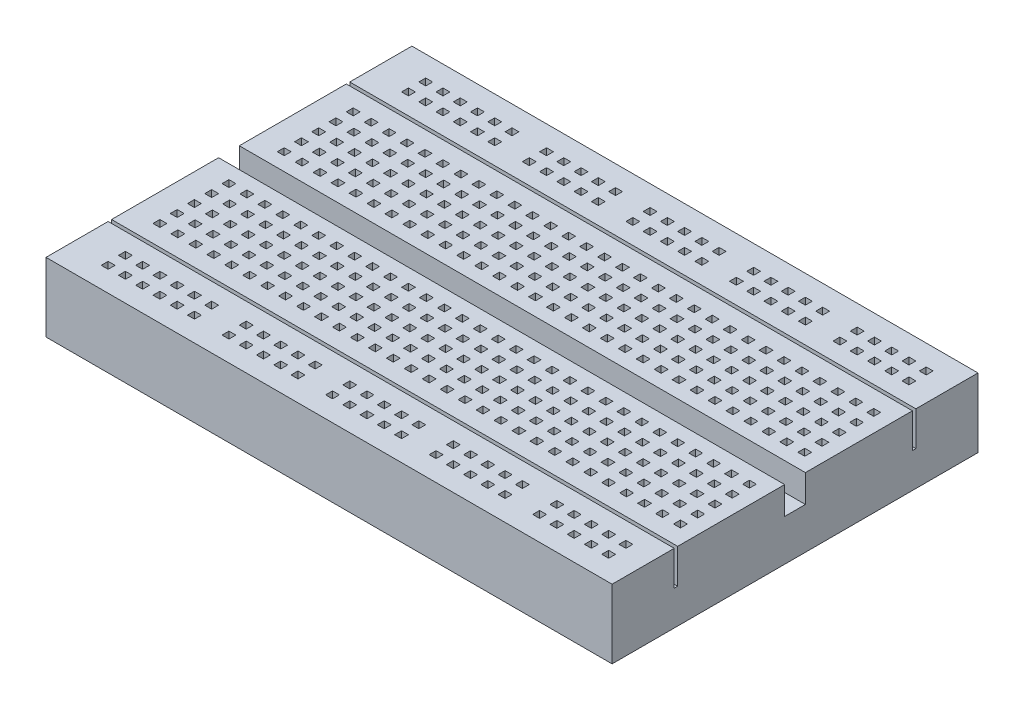
from build123d import *

# Parameters (mm, degrees)
SKETCH_1_W          = 82
SKETCH_1_H          = 53
EXTRUDE_1_DEPTH     = 10
SKETCH_2_W          = 82
SKETCH_2_H          = 3
CUT_EXTRUDE_1_DEPTH = 4
SKETCH_3_W          = 1
SKETCH_3_H          = 1
CUT_EXTRUDE_2_DEPTH = 5
SKETCH_4_W          = 1
SKETCH_4_H          = 1
CUT_EXTRUDE_3_DEPTH = 5
SKETCH_5_W          = 82
SKETCH_5_H          = 0.5
CUT_EXTRUDE_4_DEPTH = 5


with BuildPart() as part:
    # Эскиз1 → Бобышка-Вытянуть1 (new body)
    with BuildSketch(Plane(origin=(0, 0, 0), x_dir=(1, 0, 0), z_dir=(0, 1, 0))):
        Rectangle(SKETCH_1_W, SKETCH_1_H)
    extrude(amount=EXTRUDE_1_DEPTH)

    # Эскиз2 → Вырез-Вытянуть1 (cut)
    with BuildSketch(Plane(origin=(0, 10, 0), x_dir=(1, 0, 0), z_dir=(0, 1, 0))):
        Rectangle(SKETCH_2_W, SKETCH_2_H)
    extrude(amount=-CUT_EXTRUDE_1_DEPTH, mode=Mode.SUBTRACT)

    # Эскиз3 → Вырез-Вытянуть2 (cut)
    with BuildSketch(Plane(origin=(0, 10, 0), x_dir=(1, 0, 0), z_dir=(0, 1, 0))):
        with Locations((-35.5, -23)):
            Rectangle(SKETCH_3_W, SKETCH_3_H)
        with Locations((-33, -23)):
            Rectangle(SKETCH_3_W, SKETCH_3_H)
        with Locations((-30.5, -23)):
            Rectangle(SKETCH_3_W, SKETCH_3_H)
        with Locations((-28, -23)):
            Rectangle(SKETCH_3_W, SKETCH_3_H)
        with Locations((-25.5, -23)):
            Rectangle(SKETCH_3_W, SKETCH_3_H)
        with Locations((-23, -23)):
            Rectangle(SKETCH_3_W, SKETCH_3_H)
        with Locations((-18, -23)):
            Rectangle(SKETCH_3_W, SKETCH_3_H)
        with Locations((-15.5, -23)):
            Rectangle(SKETCH_3_W, SKETCH_3_H)
        with Locations((-13, -23)):
            Rectangle(SKETCH_3_W, SKETCH_3_H)
        with Locations((-10.5, -23)):
            Rectangle(SKETCH_3_W, SKETCH_3_H)
        with Locations((-8, -23)):
            Rectangle(SKETCH_3_W, SKETCH_3_H)
        with Locations((-3, -23)):
            Rectangle(SKETCH_3_W, SKETCH_3_H)
        with Locations((-0.5, -23)):
            Rectangle(SKETCH_3_W, SKETCH_3_H)
        with Locations((2, -23)):
            Rectangle(SKETCH_3_W, SKETCH_3_H)
        with Locations((4.5, -23)):
            Rectangle(SKETCH_3_W, SKETCH_3_H)
        with Locations((7, -23)):
            Rectangle(SKETCH_3_W, SKETCH_3_H)
        with Locations((12, -23)):
            Rectangle(SKETCH_3_W, SKETCH_3_H)
        with Locations((14.5, -23)):
            Rectangle(SKETCH_3_W, SKETCH_3_H)
        with Locations((17, -23)):
            Rectangle(SKETCH_3_W, SKETCH_3_H)
        with Locations((19.5, -23)):
            Rectangle(SKETCH_3_W, SKETCH_3_H)
        with Locations((22, -23)):
            Rectangle(SKETCH_3_W, SKETCH_3_H)
        with Locations((27, -23)):
            Rectangle(SKETCH_3_W, SKETCH_3_H)
        with Locations((29.5, -23)):
            Rectangle(SKETCH_3_W, SKETCH_3_H)
        with Locations((32, -23)):
            Rectangle(SKETCH_3_W, SKETCH_3_H)
        with Locations((34.5, -23)):
            Rectangle(SKETCH_3_W, SKETCH_3_H)
        with Locations((37, -23)):
            Rectangle(SKETCH_3_W, SKETCH_3_H)
        with Locations((-33, -20.5)):
            Rectangle(SKETCH_3_W, SKETCH_3_H)
        with Locations((-30.5, -20.5)):
            Rectangle(SKETCH_3_W, SKETCH_3_H)
        with Locations((-28, -20.5)):
            Rectangle(SKETCH_3_W, SKETCH_3_H)
        with Locations((-25.5, -20.5)):
            Rectangle(SKETCH_3_W, SKETCH_3_H)
        with Locations((-23, -20.5)):
            Rectangle(SKETCH_3_W, SKETCH_3_H)
        with Locations((-18, -20.5)):
            Rectangle(SKETCH_3_W, SKETCH_3_H)
        with Locations((-15.5, -20.5)):
            Rectangle(SKETCH_3_W, SKETCH_3_H)
        with Locations((-13, -20.5)):
            Rectangle(SKETCH_3_W, SKETCH_3_H)
        with Locations((-10.5, -20.5)):
            Rectangle(SKETCH_3_W, SKETCH_3_H)
        with Locations((-8, -20.5)):
            Rectangle(SKETCH_3_W, SKETCH_3_H)
        with Locations((-3, -20.5)):
            Rectangle(SKETCH_3_W, SKETCH_3_H)
        with Locations((-0.5, -20.5)):
            Rectangle(SKETCH_3_W, SKETCH_3_H)
        with Locations((2, -20.5)):
            Rectangle(SKETCH_3_W, SKETCH_3_H)
        with Locations((4.5, -20.5)):
            Rectangle(SKETCH_3_W, SKETCH_3_H)
        with Locations((7, -20.5)):
            Rectangle(SKETCH_3_W, SKETCH_3_H)
        with Locations((12, -20.5)):
            Rectangle(SKETCH_3_W, SKETCH_3_H)
        with Locations((14.5, -20.5)):
            Rectangle(SKETCH_3_W, SKETCH_3_H)
        with Locations((17, -20.5)):
            Rectangle(SKETCH_3_W, SKETCH_3_H)
        with Locations((19.5, -20.5)):
            Rectangle(SKETCH_3_W, SKETCH_3_H)
        with Locations((22, -20.5)):
            Rectangle(SKETCH_3_W, SKETCH_3_H)
        with Locations((27, -20.5)):
            Rectangle(SKETCH_3_W, SKETCH_3_H)
        with Locations((29.5, -20.5)):
            Rectangle(SKETCH_3_W, SKETCH_3_H)
        with Locations((32, -20.5)):
            Rectangle(SKETCH_3_W, SKETCH_3_H)
        with Locations((34.5, -20.5)):
            Rectangle(SKETCH_3_W, SKETCH_3_H)
        with Locations((37, -20.5)):
            Rectangle(SKETCH_3_W, SKETCH_3_H)
        with Locations((-35.5, -20.5)):
            Rectangle(SKETCH_3_W, SKETCH_3_H)
    cut_extrude_2 = extrude(amount=-CUT_EXTRUDE_2_DEPTH, mode=Mode.SUBTRACT)

    # Эскиз4 → Вырез-Вытянуть3 (cut)
    with BuildSketch(Plane(origin=(0, 10, 0), x_dir=(1, 0, 0), z_dir=(0, 1, 0))):
        with Locations((-37, -14)):
            Rectangle(SKETCH_4_W, SKETCH_4_H)
        with Locations((-34.4, -14)):
            Rectangle(SKETCH_4_W, SKETCH_4_H)
        with Locations((-31.8, -14)):
            Rectangle(SKETCH_4_W, SKETCH_4_H)
        with Locations((-29.2, -14)):
            Rectangle(SKETCH_4_W, SKETCH_4_H)
        with Locations((-26.6, -14)):
            Rectangle(SKETCH_4_W, SKETCH_4_H)
        with Locations((-24, -14)):
            Rectangle(SKETCH_4_W, SKETCH_4_H)
        with Locations((-21.4, -14)):
            Rectangle(SKETCH_4_W, SKETCH_4_H)
        with Locations((-18.8, -14)):
            Rectangle(SKETCH_4_W, SKETCH_4_H)
        with Locations((-16.2, -14)):
            Rectangle(SKETCH_4_W, SKETCH_4_H)
        with Locations((-13.6, -14)):
            Rectangle(SKETCH_4_W, SKETCH_4_H)
        with Locations((-11, -14)):
            Rectangle(SKETCH_4_W, SKETCH_4_H)
        with Locations((-8.4, -14)):
            Rectangle(SKETCH_4_W, SKETCH_4_H)
        with Locations((-5.8, -14)):
            Rectangle(SKETCH_4_W, SKETCH_4_H)
        with Locations((-3.2, -14)):
            Rectangle(SKETCH_4_W, SKETCH_4_H)
        with Locations((-0.6, -14)):
            Rectangle(SKETCH_4_W, SKETCH_4_H)
        with Locations((2, -14)):
            Rectangle(SKETCH_4_W, SKETCH_4_H)
        with Locations((4.6, -14)):
            Rectangle(SKETCH_4_W, SKETCH_4_H)
        with Locations((7.2, -14)):
            Rectangle(SKETCH_4_W, SKETCH_4_H)
        with Locations((9.8, -14)):
            Rectangle(SKETCH_4_W, SKETCH_4_H)
        with Locations((12.4, -14)):
            Rectangle(SKETCH_4_W, SKETCH_4_H)
        with Locations((15, -14)):
            Rectangle(SKETCH_4_W, SKETCH_4_H)
        with Locations((17.6, -14)):
            Rectangle(SKETCH_4_W, SKETCH_4_H)
        with Locations((20.2, -14)):
            Rectangle(SKETCH_4_W, SKETCH_4_H)
        with Locations((22.8, -14)):
            Rectangle(SKETCH_4_W, SKETCH_4_H)
        with Locations((25.4, -14)):
            Rectangle(SKETCH_4_W, SKETCH_4_H)
        with Locations((28, -14)):
            Rectangle(SKETCH_4_W, SKETCH_4_H)
        with Locations((30.6, -14)):
            Rectangle(SKETCH_4_W, SKETCH_4_H)
        with Locations((33.2, -14)):
            Rectangle(SKETCH_4_W, SKETCH_4_H)
        with Locations((35.8, -14)):
            Rectangle(SKETCH_4_W, SKETCH_4_H)
        with Locations((38.4, -14)):
            Rectangle(SKETCH_4_W, SKETCH_4_H)
        with Locations((-34.4, -11.5)):
            Rectangle(SKETCH_4_W, SKETCH_4_H)
        with Locations((-31.8, -11.5)):
            Rectangle(SKETCH_4_W, SKETCH_4_H)
        with Locations((-29.2, -11.5)):
            Rectangle(SKETCH_4_W, SKETCH_4_H)
        with Locations((-26.6, -11.5)):
            Rectangle(SKETCH_4_W, SKETCH_4_H)
        with Locations((-24, -11.5)):
            Rectangle(SKETCH_4_W, SKETCH_4_H)
        with Locations((-21.4, -11.5)):
            Rectangle(SKETCH_4_W, SKETCH_4_H)
        with Locations((-18.8, -11.5)):
            Rectangle(SKETCH_4_W, SKETCH_4_H)
        with Locations((-16.2, -11.5)):
            Rectangle(SKETCH_4_W, SKETCH_4_H)
        with Locations((-13.6, -11.5)):
            Rectangle(SKETCH_4_W, SKETCH_4_H)
        with Locations((-11, -11.5)):
            Rectangle(SKETCH_4_W, SKETCH_4_H)
        with Locations((-8.4, -11.5)):
            Rectangle(SKETCH_4_W, SKETCH_4_H)
        with Locations((-5.8, -11.5)):
            Rectangle(SKETCH_4_W, SKETCH_4_H)
        with Locations((-3.2, -11.5)):
            Rectangle(SKETCH_4_W, SKETCH_4_H)
        with Locations((-0.6, -11.5)):
            Rectangle(SKETCH_4_W, SKETCH_4_H)
        with Locations((2, -11.5)):
            Rectangle(SKETCH_4_W, SKETCH_4_H)
        with Locations((4.6, -11.5)):
            Rectangle(SKETCH_4_W, SKETCH_4_H)
        with Locations((7.2, -11.5)):
            Rectangle(SKETCH_4_W, SKETCH_4_H)
        with Locations((9.8, -11.5)):
            Rectangle(SKETCH_4_W, SKETCH_4_H)
        with Locations((12.4, -11.5)):
            Rectangle(SKETCH_4_W, SKETCH_4_H)
        with Locations((15, -11.5)):
            Rectangle(SKETCH_4_W, SKETCH_4_H)
        with Locations((17.6, -11.5)):
            Rectangle(SKETCH_4_W, SKETCH_4_H)
        with Locations((20.2, -11.5)):
            Rectangle(SKETCH_4_W, SKETCH_4_H)
        with Locations((22.8, -11.5)):
            Rectangle(SKETCH_4_W, SKETCH_4_H)
        with Locations((25.4, -11.5)):
            Rectangle(SKETCH_4_W, SKETCH_4_H)
        with Locations((28, -11.5)):
            Rectangle(SKETCH_4_W, SKETCH_4_H)
        with Locations((30.6, -11.5)):
            Rectangle(SKETCH_4_W, SKETCH_4_H)
        with Locations((33.2, -11.5)):
            Rectangle(SKETCH_4_W, SKETCH_4_H)
        with Locations((35.8, -11.5)):
            Rectangle(SKETCH_4_W, SKETCH_4_H)
        with Locations((38.4, -11.5)):
            Rectangle(SKETCH_4_W, SKETCH_4_H)
        with Locations((-34.4, -9)):
            Rectangle(SKETCH_4_W, SKETCH_4_H)
        with Locations((-31.8, -9)):
            Rectangle(SKETCH_4_W, SKETCH_4_H)
        with Locations((-29.2, -9)):
            Rectangle(SKETCH_4_W, SKETCH_4_H)
        with Locations((-26.6, -9)):
            Rectangle(SKETCH_4_W, SKETCH_4_H)
        with Locations((-24, -9)):
            Rectangle(SKETCH_4_W, SKETCH_4_H)
        with Locations((-21.4, -9)):
            Rectangle(SKETCH_4_W, SKETCH_4_H)
        with Locations((-18.8, -9)):
            Rectangle(SKETCH_4_W, SKETCH_4_H)
        with Locations((-16.2, -9)):
            Rectangle(SKETCH_4_W, SKETCH_4_H)
        with Locations((-13.6, -9)):
            Rectangle(SKETCH_4_W, SKETCH_4_H)
        with Locations((-11, -9)):
            Rectangle(SKETCH_4_W, SKETCH_4_H)
        with Locations((-8.4, -9)):
            Rectangle(SKETCH_4_W, SKETCH_4_H)
        with Locations((-5.8, -9)):
            Rectangle(SKETCH_4_W, SKETCH_4_H)
        with Locations((-3.2, -9)):
            Rectangle(SKETCH_4_W, SKETCH_4_H)
        with Locations((-0.6, -9)):
            Rectangle(SKETCH_4_W, SKETCH_4_H)
        with Locations((2, -9)):
            Rectangle(SKETCH_4_W, SKETCH_4_H)
        with Locations((4.6, -9)):
            Rectangle(SKETCH_4_W, SKETCH_4_H)
        with Locations((7.2, -9)):
            Rectangle(SKETCH_4_W, SKETCH_4_H)
        with Locations((9.8, -9)):
            Rectangle(SKETCH_4_W, SKETCH_4_H)
        with Locations((12.4, -9)):
            Rectangle(SKETCH_4_W, SKETCH_4_H)
        with Locations((15, -9)):
            Rectangle(SKETCH_4_W, SKETCH_4_H)
        with Locations((17.6, -9)):
            Rectangle(SKETCH_4_W, SKETCH_4_H)
        with Locations((20.2, -9)):
            Rectangle(SKETCH_4_W, SKETCH_4_H)
        with Locations((22.8, -9)):
            Rectangle(SKETCH_4_W, SKETCH_4_H)
        with Locations((25.4, -9)):
            Rectangle(SKETCH_4_W, SKETCH_4_H)
        with Locations((28, -9)):
            Rectangle(SKETCH_4_W, SKETCH_4_H)
        with Locations((30.6, -9)):
            Rectangle(SKETCH_4_W, SKETCH_4_H)
        with Locations((33.2, -9)):
            Rectangle(SKETCH_4_W, SKETCH_4_H)
        with Locations((35.8, -9)):
            Rectangle(SKETCH_4_W, SKETCH_4_H)
        with Locations((38.4, -9)):
            Rectangle(SKETCH_4_W, SKETCH_4_H)
        with Locations((-34.4, -6.5)):
            Rectangle(SKETCH_4_W, SKETCH_4_H)
        with Locations((-31.8, -6.5)):
            Rectangle(SKETCH_4_W, SKETCH_4_H)
        with Locations((-29.2, -6.5)):
            Rectangle(SKETCH_4_W, SKETCH_4_H)
        with Locations((-26.6, -6.5)):
            Rectangle(SKETCH_4_W, SKETCH_4_H)
        with Locations((-24, -6.5)):
            Rectangle(SKETCH_4_W, SKETCH_4_H)
        with Locations((-21.4, -6.5)):
            Rectangle(SKETCH_4_W, SKETCH_4_H)
        with Locations((-18.8, -6.5)):
            Rectangle(SKETCH_4_W, SKETCH_4_H)
        with Locations((-16.2, -6.5)):
            Rectangle(SKETCH_4_W, SKETCH_4_H)
        with Locations((-13.6, -6.5)):
            Rectangle(SKETCH_4_W, SKETCH_4_H)
        with Locations((-11, -6.5)):
            Rectangle(SKETCH_4_W, SKETCH_4_H)
        with Locations((-8.4, -6.5)):
            Rectangle(SKETCH_4_W, SKETCH_4_H)
        with Locations((-5.8, -6.5)):
            Rectangle(SKETCH_4_W, SKETCH_4_H)
        with Locations((-3.2, -6.5)):
            Rectangle(SKETCH_4_W, SKETCH_4_H)
        with Locations((-0.6, -6.5)):
            Rectangle(SKETCH_4_W, SKETCH_4_H)
        with Locations((2, -6.5)):
            Rectangle(SKETCH_4_W, SKETCH_4_H)
        with Locations((4.6, -6.5)):
            Rectangle(SKETCH_4_W, SKETCH_4_H)
        with Locations((7.2, -6.5)):
            Rectangle(SKETCH_4_W, SKETCH_4_H)
        with Locations((9.8, -6.5)):
            Rectangle(SKETCH_4_W, SKETCH_4_H)
        with Locations((12.4, -6.5)):
            Rectangle(SKETCH_4_W, SKETCH_4_H)
        with Locations((15, -6.5)):
            Rectangle(SKETCH_4_W, SKETCH_4_H)
        with Locations((17.6, -6.5)):
            Rectangle(SKETCH_4_W, SKETCH_4_H)
        with Locations((20.2, -6.5)):
            Rectangle(SKETCH_4_W, SKETCH_4_H)
        with Locations((22.8, -6.5)):
            Rectangle(SKETCH_4_W, SKETCH_4_H)
        with Locations((25.4, -6.5)):
            Rectangle(SKETCH_4_W, SKETCH_4_H)
        with Locations((28, -6.5)):
            Rectangle(SKETCH_4_W, SKETCH_4_H)
        with Locations((30.6, -6.5)):
            Rectangle(SKETCH_4_W, SKETCH_4_H)
        with Locations((33.2, -6.5)):
            Rectangle(SKETCH_4_W, SKETCH_4_H)
        with Locations((35.8, -6.5)):
            Rectangle(SKETCH_4_W, SKETCH_4_H)
        with Locations((38.4, -6.5)):
            Rectangle(SKETCH_4_W, SKETCH_4_H)
        with Locations((-34.4, -4)):
            Rectangle(SKETCH_4_W, SKETCH_4_H)
        with Locations((-31.8, -4)):
            Rectangle(SKETCH_4_W, SKETCH_4_H)
        with Locations((-29.2, -4)):
            Rectangle(SKETCH_4_W, SKETCH_4_H)
        with Locations((-26.6, -4)):
            Rectangle(SKETCH_4_W, SKETCH_4_H)
        with Locations((-24, -4)):
            Rectangle(SKETCH_4_W, SKETCH_4_H)
        with Locations((-21.4, -4)):
            Rectangle(SKETCH_4_W, SKETCH_4_H)
        with Locations((-18.8, -4)):
            Rectangle(SKETCH_4_W, SKETCH_4_H)
        with Locations((-16.2, -4)):
            Rectangle(SKETCH_4_W, SKETCH_4_H)
        with Locations((-13.6, -4)):
            Rectangle(SKETCH_4_W, SKETCH_4_H)
        with Locations((-11, -4)):
            Rectangle(SKETCH_4_W, SKETCH_4_H)
        with Locations((-8.4, -4)):
            Rectangle(SKETCH_4_W, SKETCH_4_H)
        with Locations((-5.8, -4)):
            Rectangle(SKETCH_4_W, SKETCH_4_H)
        with Locations((-3.2, -4)):
            Rectangle(SKETCH_4_W, SKETCH_4_H)
        with Locations((-0.6, -4)):
            Rectangle(SKETCH_4_W, SKETCH_4_H)
        with Locations((2, -4)):
            Rectangle(SKETCH_4_W, SKETCH_4_H)
        with Locations((4.6, -4)):
            Rectangle(SKETCH_4_W, SKETCH_4_H)
        with Locations((7.2, -4)):
            Rectangle(SKETCH_4_W, SKETCH_4_H)
        with Locations((9.8, -4)):
            Rectangle(SKETCH_4_W, SKETCH_4_H)
        with Locations((12.4, -4)):
            Rectangle(SKETCH_4_W, SKETCH_4_H)
        with Locations((15, -4)):
            Rectangle(SKETCH_4_W, SKETCH_4_H)
        with Locations((17.6, -4)):
            Rectangle(SKETCH_4_W, SKETCH_4_H)
        with Locations((20.2, -4)):
            Rectangle(SKETCH_4_W, SKETCH_4_H)
        with Locations((22.8, -4)):
            Rectangle(SKETCH_4_W, SKETCH_4_H)
        with Locations((25.4, -4)):
            Rectangle(SKETCH_4_W, SKETCH_4_H)
        with Locations((28, -4)):
            Rectangle(SKETCH_4_W, SKETCH_4_H)
        with Locations((30.6, -4)):
            Rectangle(SKETCH_4_W, SKETCH_4_H)
        with Locations((33.2, -4)):
            Rectangle(SKETCH_4_W, SKETCH_4_H)
        with Locations((35.8, -4)):
            Rectangle(SKETCH_4_W, SKETCH_4_H)
        with Locations((38.4, -4)):
            Rectangle(SKETCH_4_W, SKETCH_4_H)
        with Locations((-37, -11.5)):
            Rectangle(SKETCH_4_W, SKETCH_4_H)
        with Locations((-37, -9)):
            Rectangle(SKETCH_4_W, SKETCH_4_H)
        with Locations((-37, -6.5)):
            Rectangle(SKETCH_4_W, SKETCH_4_H)
        with Locations((-37, -4)):
            Rectangle(SKETCH_4_W, SKETCH_4_H)
    cut_extrude_3 = extrude(amount=-CUT_EXTRUDE_3_DEPTH, mode=Mode.SUBTRACT)

    # Эскиз5 → Вырез-Вытянуть4 (cut)
    with BuildSketch(Plane(origin=(0, 10, 0), x_dir=(1, 0, 0), z_dir=(0, 1, 0))):
        with Locations((0, -17.25)):
            Rectangle(SKETCH_5_W, SKETCH_5_H)
    cut_extrude_4 = extrude(amount=-CUT_EXTRUDE_4_DEPTH, mode=Mode.SUBTRACT)

    # Зеркальное отражение2: Вырез-Вытянуть2, Вырез-Вытянуть3, Вырез-Вытянуть4 across plane
    add(cut_extrude_2.mirror(Plane.XY), mode=Mode.SUBTRACT)
    add(cut_extrude_3.mirror(Plane.XY), mode=Mode.SUBTRACT)
    add(cut_extrude_4.mirror(Plane.XY), mode=Mode.SUBTRACT)


solid = part.part
